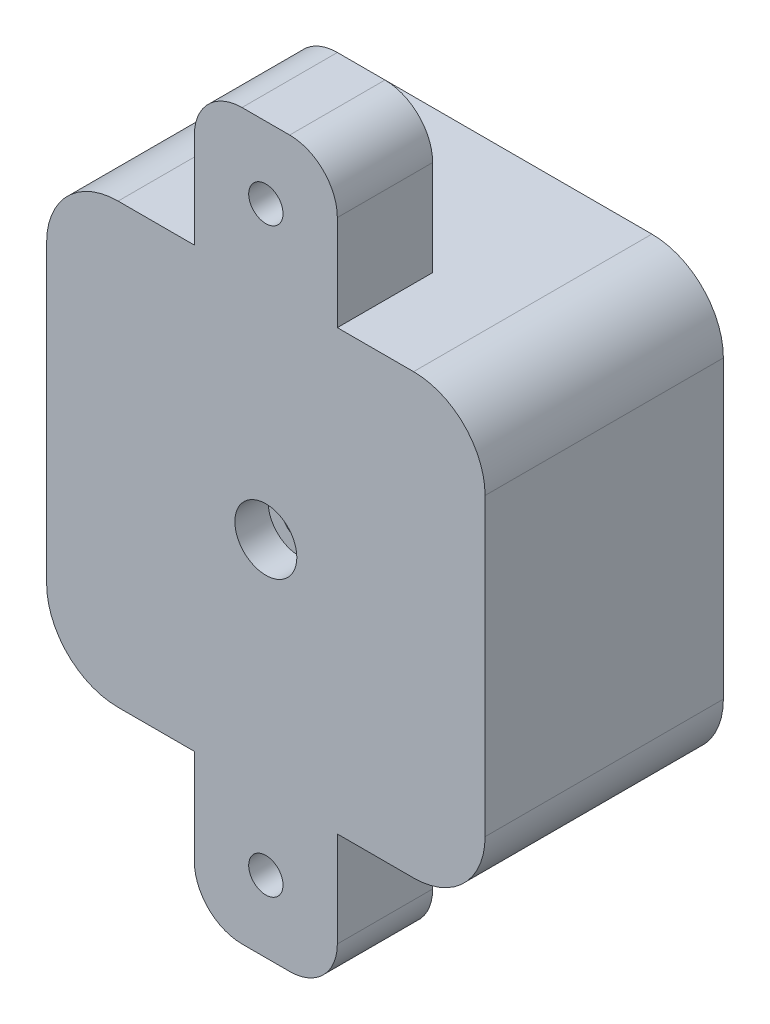
from build123d import *

# Parameters (mm, degrees)
MAIN_DEPTH               = 25
SKETCH2_R                = 20
PULLEY_HOLE_DEPTH        = 21
PULLEY_OUT_REACH         = 48
SKETCH3_W                = 10
SKETCH3_H                = 30
FIXATION_DEPTH           = 10
SKETCH5_R                = 3.5
BOSS_EXTRUDE3_DEPTH      = 4
M3_CLEARANCE_HOLE2_D     = 3.6
M3_CLEARANCE_HOLE2_DEPTH = 8
M3_CLEARANCE_HOLE3_D     = 3.6
M3_CLEARANCE_HOLE3_DEPTH = 10
M3_CLEARANCE_HOLE4_D     = 3.6
M3_CLEARANCE_HOLE4_DEPTH = 10
SKETCH15_R               = 3.25
CUT_EXTRUDE1_DEPTH       = 3.5


with BuildPart() as part:
    # Sketch1 → Main (new body)
    with BuildSketch(Plane.XY):
        with BuildLine():
            Line((-15.5, 23), (15.5, 23))
            ThreePointArc((15.5, 23), (20.803300859, 20.803300859), (23, 15.5))
            Line((23, 15.5), (23, -15.5))
            ThreePointArc((23, -15.5), (20.803300859, -20.803300859), (15.5, -23))
            Line((15.5, -23), (-15.5, -23))
            ThreePointArc((-15.5, -23), (-20.803300859, -20.803300859), (-23, -15.5))
            Line((-23, -15.5), (-23, 15.5))
            ThreePointArc((-23, 15.5), (-20.803300859, 20.803300859), (-15.5, 23))
        make_face()
    extrude(amount=MAIN_DEPTH)

    # Sketch2 → Pulley Hole (cut)
    with BuildSketch(Plane(origin=(0, 0, 0), x_dir=(-1, 0, 0), z_dir=(0, 0, -1))):
        Circle(SKETCH2_R)
    extrude(amount=-PULLEY_HOLE_DEPTH, mode=Mode.SUBTRACT)

    # Sketch3 → Pulley Out (cut, up to next)
    with BuildSketch(Plane.ZY.offset(23), mode=Mode.PRIVATE) as pulley_out_sk1:
        with Locations((13, 0)):
            Rectangle(SKETCH3_W, SKETCH3_H)
    pulley_out_tool1 = extrude(pulley_out_sk1.sketch, amount=-PULLEY_OUT_REACH, mode=Mode.PRIVATE) & part.part
    add(pulley_out_tool1.solids().sort_by_distance((-23, 0, 13))[0], mode=Mode.SUBTRACT)

    # Sketch4 → Fixation (add)
    with BuildSketch(Plane.XY.offset(25)):
        with BuildLine():
            Line((-7.5, -23), (7.5, -23))
            Line((7.5, -23), (7.5, -33))
            ThreePointArc((7.5, -33), (6.035533906, -36.535533906), (2.5, -38))
            Line((2.5, -38), (-2.5, -38))
            ThreePointArc((-2.5, -38), (-6.035533906, -36.535533906), (-7.5, -33))
            Line((-7.5, -33), (-7.5, -23))
        make_face()
        with BuildLine():
            Line((-7.5, 23), (7.5, 23))
            Line((7.5, 23), (7.5, 33))
            ThreePointArc((7.5, 33), (6.035533906, 36.535533906), (2.5, 38))
            Line((2.5, 38), (-2.5, 38))
            ThreePointArc((-2.5, 38), (-6.035533906, 36.535533906), (-7.5, 33))
            Line((-7.5, 33), (-7.5, 23))
        make_face()
    extrude(amount=-FIXATION_DEPTH)

    # Sketch5 → Boss-Extrude3 (add)
    with BuildSketch(Plane(origin=(0, 0, 21), x_dir=(-1, 0, 0), z_dir=(0, 0, -1))):
        Circle(SKETCH5_R)
    extrude(amount=BOSS_EXTRUDE3_DEPTH)

    # M3 Clearance Hole2
    with Locations(Plane.XY.offset(25)):
        with Locations((0, 0)):
            Hole(M3_CLEARANCE_HOLE2_D / 2, depth=M3_CLEARANCE_HOLE2_DEPTH)

    # M3 Clearance Hole3
    with Locations(Plane(origin=(0, -30.5, 25), x_dir=(1, 0, 0), z_dir=(0, 0, 1))):
        with Locations((0, 0)):
            Hole(M3_CLEARANCE_HOLE3_D / 2, depth=M3_CLEARANCE_HOLE3_DEPTH)

    # M3 Clearance Hole4
    with Locations(Plane(origin=(0, 30.5, 25), x_dir=(1, 0, 0), z_dir=(0, 0, 1))):
        with Locations((0, 0)):
            Hole(M3_CLEARANCE_HOLE4_D / 2, depth=M3_CLEARANCE_HOLE4_DEPTH)

    # Sketch15 → Cut-Extrude1 (cut)
    with BuildSketch(Plane.XY.offset(25)):
        Circle(SKETCH15_R)
    extrude(amount=-CUT_EXTRUDE1_DEPTH, mode=Mode.SUBTRACT)


solid = part.part
